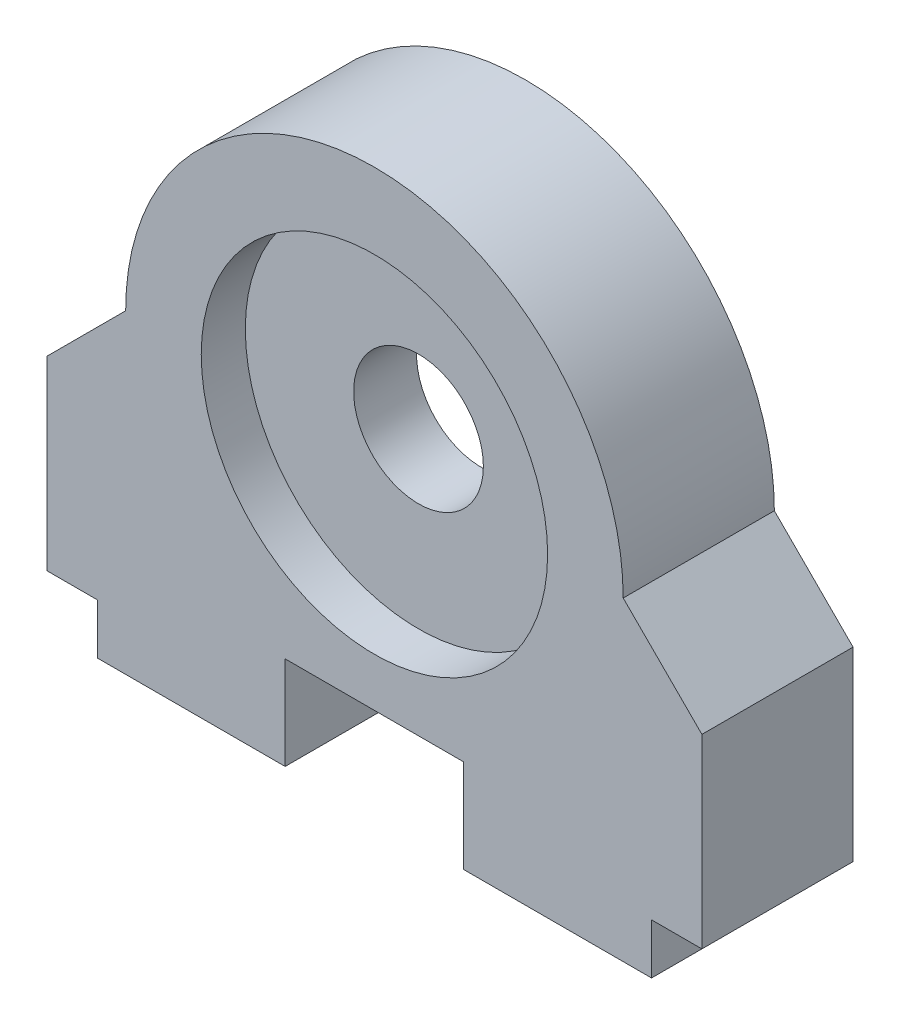
from build123d import *

# Parameters (mm, degrees)
SKETCH1_R                = 8.73125
BOSS_EXTRUDE1_DEPTH      = 7.62
SKETCH3_R                = 8.7376
SKETCH3_R_2              = 3.27025
BOSS_EXTRUDE2_DEPTH      = 1.5875
BOSS_EXTRUDE2_DEPTH_BACK = 1.5875
SKETCH4_R                = 1.98374
CUT_EXTRUDE1_DEPTH       = 10.16


with BuildPart() as part:
    # Sketch1 → Boss-Extrude1 (new body)
    with BuildSketch(Plane.XY):
        with BuildLine():
            Line((4.5, 4.699), (-4.5, 4.699))
            Line((-4.5, 4.699), (-4.5, 0))
            Line((-4.5, 0), (-13.97, 0))
            Line((-13.97, 0), (-13.97, 2.54))
            Line((-13.97, 2.54), (-16.51, 2.54))
            Line((-16.51, 2.54), (-16.51, 11.90625))
            Line((-16.51, 11.90625), (-12.54125, 15.875))
            ThreePointArc((-12.54125, 15.875), (0, 28.41625), (12.54125, 15.875))
            Line((12.54125, 15.875), (16.51, 11.90625))
            Line((16.51, 11.90625), (16.51, 2.54))
            Line((16.51, 2.54), (13.97, 2.54))
            Line((13.97, 2.54), (13.97, 0))
            Line((13.97, 0), (4.5, 0))
            Line((4.5, 0), (4.5, 4.699))
        make_face()
        with Locations((0, 15.875)):
            Circle(SKETCH1_R, mode=Mode.SUBTRACT)
    extrude(amount=BOSS_EXTRUDE1_DEPTH)

    # Sketch3 → Boss-Extrude2 (add, two sides)
    with BuildSketch(Plane.XY.offset(3.81)) as boss_extrude2_sk:
        with Locations((0, 15.875)):
            Circle(SKETCH3_R)
        with Locations((0, 15.875)):
            Circle(SKETCH3_R_2, mode=Mode.SUBTRACT)
    extrude(amount=BOSS_EXTRUDE2_DEPTH)
    extrude(boss_extrude2_sk.sketch, amount=-BOSS_EXTRUDE2_DEPTH_BACK)

    # Sketch4 → Cut-Extrude1 (cut)
    with BuildSketch(Plane(origin=(0, 0, 0), x_dir=(-1, 0, 0), z_dir=(0, -1, 0))):
        with Locations((-10.16, -3.81)):
            Circle(SKETCH4_R)
        with Locations((10.16, -3.81)):
            Circle(SKETCH4_R)
    extrude(amount=-CUT_EXTRUDE1_DEPTH, mode=Mode.SUBTRACT)


solid = part.part
